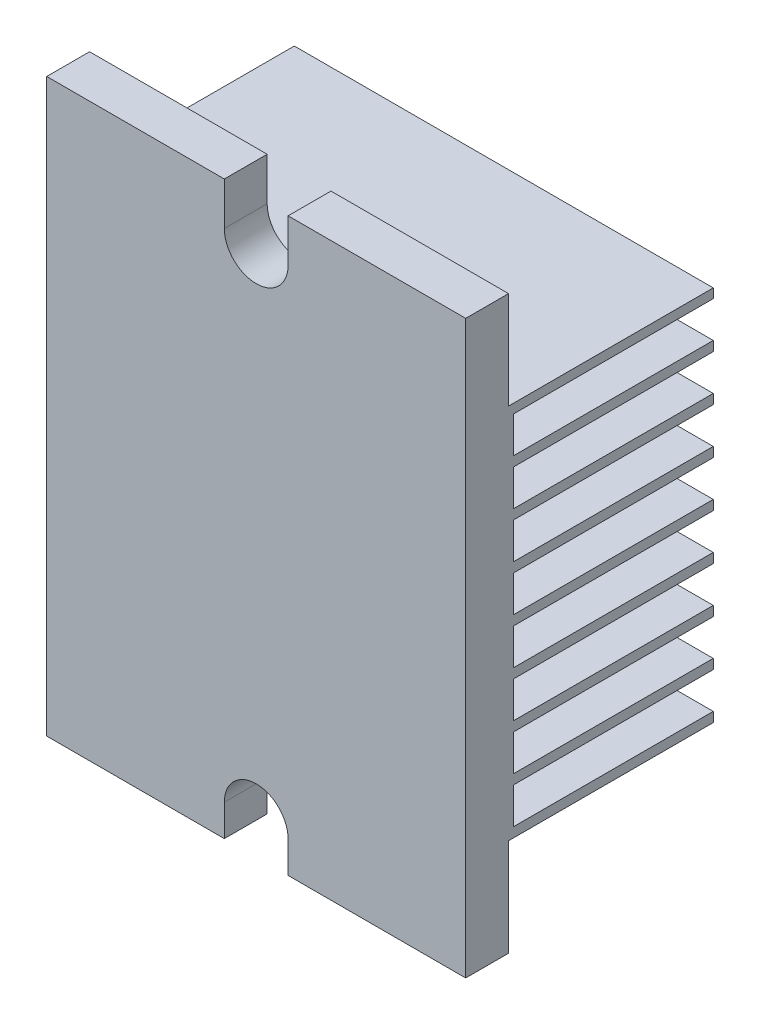
from build123d import *

# Parameters (mm, degrees)
SCHIZZO1_W                   = 44
SCHIZZO1_H                   = 60
ESTRUSIONE_ESTRUSIONE1_DEPTH = 26
SCHIZZO2_W                   = 21
SCHIZZO2_H                   = 3.8
TAGLIO_ESTRUSIONE1_DEPTH     = 45
RIPETIZIONE_A_L1_COUNT       = 8
RIPETIZIONE_A_L1_PITCH       = 4.82
SCHIZZO3_W                   = 21.5
SCHIZZO3_H                   = 10.23
TAGLIO_ESTRUSIONE2_DEPTH     = 45
TAGLIO_ESTRUSIONE4_DEPTH     = 5.5


with BuildPart() as part:
    # Schizzo1 → Estrusione-Estrusione1 (new body)
    with BuildSketch(Plane.XY):
        Rectangle(SCHIZZO1_W, SCHIZZO1_H)
    extrude(amount=ESTRUSIONE_ESTRUSIONE1_DEPTH)

    # Schizzo2 → Taglio-Estrusione1 (cut, through all)
    with BuildSketch(Plane.ZY.offset(22)):
        with Locations((10.5, -16.85)):
            Rectangle(SCHIZZO2_W, SCHIZZO2_H)
    taglio_estrusione1 = extrude(amount=-TAGLIO_ESTRUSIONE1_DEPTH, mode=Mode.SUBTRACT)

    # Ripetizione a L1: Taglio-Estrusione1 ×8
    with Locations(*[(0, i * RIPETIZIONE_A_L1_PITCH, 0) for i in range(1, RIPETIZIONE_A_L1_COUNT)]):
        add(taglio_estrusione1, mode=Mode.SUBTRACT)

    # Schizzo3 → Taglio-Estrusione2 (cut, through all)
    with BuildSketch(Plane(origin=(22, 0, 0), x_dir=(0, 0, -1), z_dir=(1, 0, 0))):
        with Locations((-10.75, -24.885)):
            Rectangle(SCHIZZO3_W, SCHIZZO3_H)
        with Locations((-10.75, 24.885)):
            Rectangle(SCHIZZO3_W, SCHIZZO3_H)
    extrude(amount=-TAGLIO_ESTRUSIONE2_DEPTH, mode=Mode.SUBTRACT)

    # Schizzo5 → Taglio-Estrusione4 (cut, through all)
    with BuildSketch(Plane(origin=(0, 0, 21.5), x_dir=(-1, 0, 0), z_dir=(0, 0, -1))):
        with BuildLine():
            Line((3.35, 34.5), (3.35, 25.5))
            ThreePointArc((3.35, 25.5), (0, 22.15), (-3.35, 25.5))
            Line((-3.35, 25.5), (-3.35, 34.5))
            ThreePointArc((-3.35, 34.5), (0, 37.85), (3.35, 34.5))
        make_face()
        with BuildLine():
            Line((-3.35, -33.313801036), (-3.35, -26.686198964))
            ThreePointArc((-3.35, -26.686198964), (0, -23.336198964), (3.35, -26.686198964))
            Line((3.35, -26.686198964), (3.35, -33.313801036))
            ThreePointArc((3.35, -33.313801036), (0, -36.663801036), (-3.35, -33.313801036))
        make_face()
    extrude(amount=-TAGLIO_ESTRUSIONE4_DEPTH, mode=Mode.SUBTRACT)


solid = part.part
